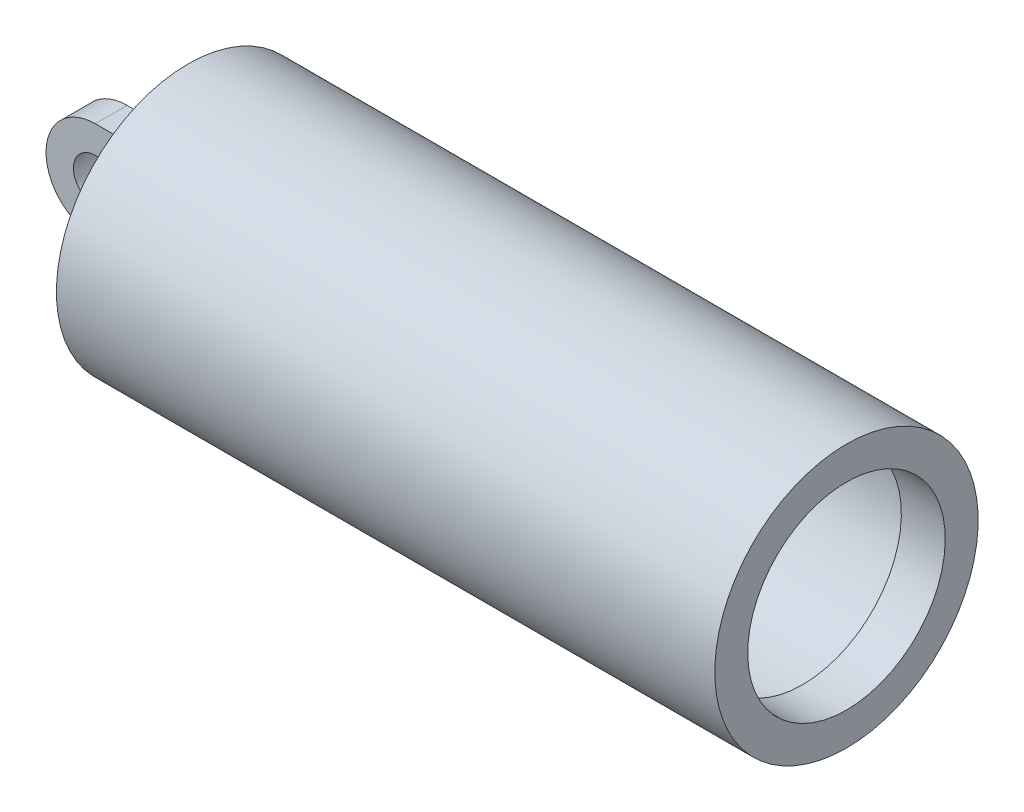
from build123d import *

# Parameters (mm, degrees)
BOSS_EXTRUDE1_DEPTH      = 7.25
BOSS_EXTRUDE1_DEPTH_BACK = 7.25
SKETCH3_R                = 10


with BuildPart() as part:
    # Sketch1 → Revolve1 (revolve)
    with BuildSketch(Plane.XY):
        Polygon((150, 45), (150, 60), (-150, 60), (-150, 0), (-130, 0), (-130, 55), (130, 55), (130, 45), align=None)
    revolve(axis=Axis((-150, 0, 0), (1, 0, 0)))

    # Sketch3 → Boss-Extrude1 (add, two sides: drawn at the far end of the back side and taken through both)
    with BuildSketch(Plane.XY.offset(-BOSS_EXTRUDE1_DEPTH_BACK)):
        with BuildLine():
            Line((-150, 22.5), (-150, -22.5))
            Line((-150, -22.5), (-185, -22.5))
            ThreePointArc((-185, -22.5), (-207.5, 0), (-185, 22.5))
            Line((-185, 22.5), (-150, 22.5))
        make_face()
        with Locations((-185, 0)):
            Circle(SKETCH3_R, mode=Mode.SUBTRACT)
    extrude(amount=BOSS_EXTRUDE1_DEPTH + BOSS_EXTRUDE1_DEPTH_BACK)


solid = part.part
